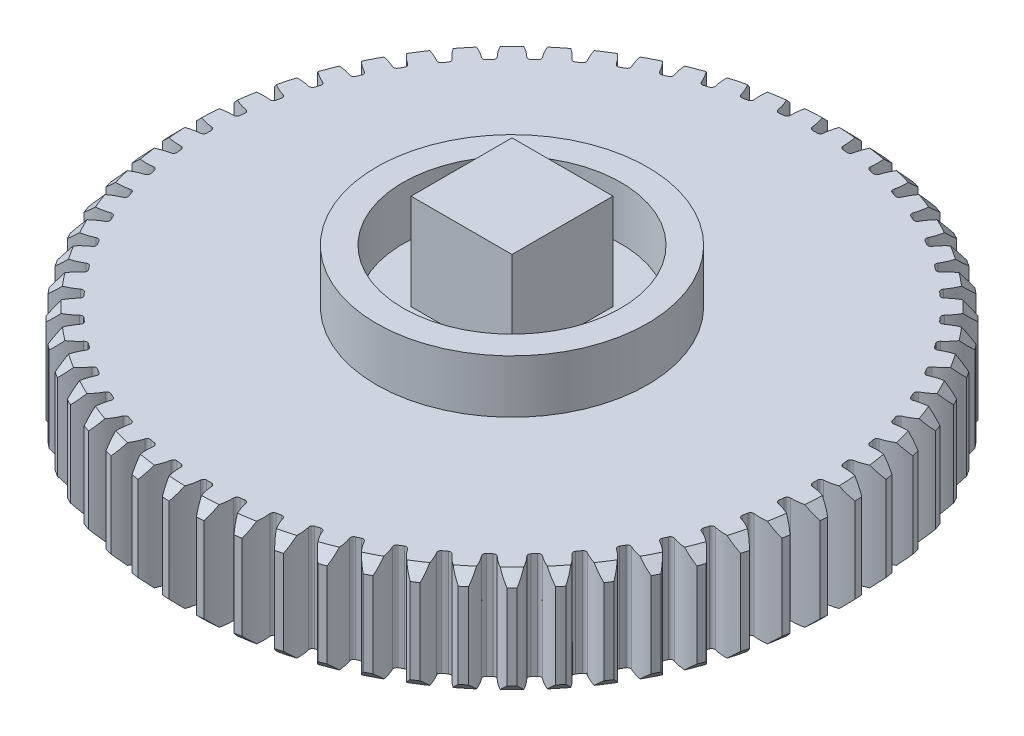
from build123d import *

# Parameters (mm, degrees)
SKETCH1_R                = 31
BOSS_EXTRUDE1_DEPTH      = 5
CUT_EXTRUDE4_DEPTH       = 6
FILLET1_R                = 0.3
CHAMFER1_SIZE            = 1
CIRPATTERN1_COUNT        = 60
FILLET1_OF_CIRPATTERN1_R = 0.3
SKETCH3_R                = 12.75
SKETCH3_R_2              = 10.25
BOSS_EXTRUDE3_DEPTH      = 5
SKETCH5_W                = 9.5
SKETCH5_H                = 9.5
BOSS_EXTRUDE4_DEPTH      = 9
SKETCH6_R                = 7.5
BOSS_EXTRUDE5_DEPTH      = 10


with BuildPart() as part:
    # Sketch1 → Boss-Extrude1 (new body, symmetric)
    with BuildSketch(Plane(origin=(0, 0, 0), x_dir=(1, 0, 0), z_dir=(0, 1, 0))):
        Circle(SKETCH1_R)
    extrude(amount=BOSS_EXTRUDE1_DEPTH, both=True)

    # Sketch2 → Cut-Extrude4 (cut, symmetric)
    with BuildSketch(Plane(origin=(0, 0, 0), x_dir=(1, 0, 0), z_dir=(0, 1, 0))):
        with BuildLine():
            ThreePointArc((-1.283727225, 30.973408666), (-0.717806781, 29.790187518), (-0.50807607, 28.495470846))
            ThreePointArc((-0.50807607, 28.495470846), (0, 28.5), (0.50807607, 28.495470846))
            ThreePointArc((0.50807607, 28.495470846), (0.717806781, 29.790187518), (1.283727225, 30.973408666))
            ThreePointArc((1.283727225, 30.973408666), (0, 31), (-1.283727225, 30.973408666))
        make_face()
    cut_extrude4 = extrude(amount=CUT_EXTRUDE4_DEPTH, both=True, mode=Mode.SUBTRACT)

    # Fillet1
    fillet1_edges = [part.edges().sort_by_distance(p)[0] for p in [
        (0.50807607, 0, -28.495470846),
        (-0.50807607, 0, -28.495470846),
    ]]
    fillet(fillet1_edges, radius=FILLET1_R)

    # Chamfer1
    chamfer1_edges = [part.edges().sort_by_distance(p)[0] for p in [
        (-21.46164551, -5, 22.369572459),
        (-21.46164551, 5, 22.369572459),
    ]]
    chamfer(chamfer1_edges, length=CHAMFER1_SIZE)

    # CirPattern1: Cut-Extrude4 ×60 about axis
    cirpattern1_axis = Axis((0, 0, 0), (0, 1, 0))
    for i in range(1, CIRPATTERN1_COUNT):
        add(cut_extrude4.rotate(cirpattern1_axis, i * 360 / CIRPATTERN1_COUNT), mode=Mode.SUBTRACT)

    # Fillet1 of CirPattern1
    fillet1_of_cirpattern1_edges = [part.edges().sort_by_distance(p)[0] for p in [
        (-2.473295002, 0, -28.392478085),
        (-3.483880553, 0, -28.286261264),
        (-5.427568136, 0, -27.978411394),
        (-6.421514913, 0, -27.767141485),
        (-8.322375697, 0, -27.257807372),
        (-9.288793811, 0, -26.943799093),
        (-11.126001569, 0, -26.238561109),
        (-12.05430274, 0, -25.825254799),
        (-13.807728639, 0, -24.93183968),
        (-14.687742206, 0, -24.42376361),
        (-16.338175345, 0, -23.351959797),
        (-17.160259695, 0, -22.754680556),
        (-18.689617583, 0, -21.516230957),
        (-19.444765787, 0, -20.83629246),
        (-20.83629246, 0, -19.444765787),
        (-21.516230957, 0, -18.689617583),
        (-22.754680556, 0, -17.160259695),
        (-23.351959797, 0, -16.338175345),
        (-24.42376361, 0, -14.687742206),
        (-24.93183968, 0, -13.807728639),
        (-25.825254799, 0, -12.05430274),
        (-26.238561109, 0, -11.126001569),
        (-26.943799093, 0, -9.288793811),
        (-27.257807372, 0, -8.322375697),
        (-27.767141485, 0, -6.421514913),
        (-27.978411394, 0, -5.427568136),
        (-28.286261264, 0, -3.483880553),
        (-28.392478085, 0, -2.473295002),
        (-28.495470846, 0, -0.50807607),
        (-28.495470846, 0, 0.50807607),
        (-28.392478085, 0, 2.473295002),
        (-28.286261264, 0, 3.483880553),
        (-27.978411394, 0, 5.427568136),
        (-27.767141485, 0, 6.421514913),
        (-27.257807372, 0, 8.322375697),
        (-26.943799093, 0, 9.288793811),
        (-26.238561109, 0, 11.126001569),
        (-25.825254799, 0, 12.05430274),
        (-24.93183968, 0, 13.807728639),
        (-24.42376361, 0, 14.687742206),
        (-23.351959797, 0, 16.338175345),
        (-22.754680556, 0, 17.160259695),
        (-21.516230957, 0, 18.689617583),
        (-20.83629246, 0, 19.444765787),
        (-19.444765787, 0, 20.83629246),
        (-18.689617583, 0, 21.516230957),
        (-17.160259695, 0, 22.754680556),
        (-16.338175345, 0, 23.351959797),
        (-14.687742206, 0, 24.42376361),
        (-13.807728639, 0, 24.93183968),
        (-12.05430274, 0, 25.825254799),
        (-11.126001569, 0, 26.238561109),
        (-9.288793811, 0, 26.943799093),
        (-8.322375697, 0, 27.257807372),
        (-6.421514913, 0, 27.767141485),
        (-5.427568136, 0, 27.978411394),
        (-3.483880553, 0, 28.286261264),
        (-2.473295002, 0, 28.392478085),
        (-0.50807607, 0, 28.495470846),
        (0.50807607, 0, 28.495470846),
        (2.473295002, 0, 28.392478085),
        (3.483880553, 0, 28.286261264),
        (5.427568136, 0, 27.978411394),
        (6.421514913, 0, 27.767141485),
        (8.322375697, 0, 27.257807372),
        (9.288793811, 0, 26.943799093),
        (11.126001569, 0, 26.238561109),
        (12.05430274, 0, 25.825254799),
        (13.807728639, 0, 24.93183968),
        (14.687742206, 0, 24.42376361),
        (16.338175345, 0, 23.351959797),
        (17.160259695, 0, 22.754680556),
        (18.689617583, 0, 21.516230957),
        (19.444765787, 0, 20.83629246),
        (20.83629246, 0, 19.444765787),
        (21.516230957, 0, 18.689617583),
        (22.754680556, 0, 17.160259695),
        (23.351959797, 0, 16.338175345),
        (24.42376361, 0, 14.687742206),
        (24.93183968, 0, 13.807728639),
        (25.825254799, 0, 12.05430274),
        (26.238561109, 0, 11.126001569),
        (26.943799093, 0, 9.288793811),
        (27.257807372, 0, 8.322375697),
        (27.767141485, 0, 6.421514913),
        (27.978411394, 0, 5.427568136),
        (28.286261264, 0, 3.483880553),
        (28.392478085, 0, 2.473295002),
        (28.495470846, 0, 0.50807607),
        (28.495470846, 0, -0.50807607),
        (28.392478085, 0, -2.473295002),
        (28.286261264, 0, -3.483880553),
        (27.978411394, 0, -5.427568136),
        (27.767141485, 0, -6.421514913),
        (27.257807372, 0, -8.322375697),
        (26.943799093, 0, -9.288793811),
        (26.238561109, 0, -11.126001569),
        (25.825254799, 0, -12.05430274),
        (24.93183968, 0, -13.807728639),
        (24.42376361, 0, -14.687742206),
        (23.351959797, 0, -16.338175345),
        (22.754680556, 0, -17.160259695),
        (21.516230957, 0, -18.689617583),
        (20.83629246, 0, -19.444765787),
        (19.444765787, 0, -20.83629246),
        (18.689617583, 0, -21.516230957),
        (17.160259695, 0, -22.754680556),
        (16.338175345, 0, -23.351959797),
        (14.687742206, 0, -24.42376361),
        (13.807728639, 0, -24.93183968),
        (12.05430274, 0, -25.825254799),
        (11.126001569, 0, -26.238561109),
        (9.288793811, 0, -26.943799093),
        (8.322375697, 0, -27.257807372),
        (6.421514913, 0, -27.767141485),
        (5.427568136, 0, -27.978411394),
        (3.483880553, 0, -28.286261264),
        (2.473295002, 0, -28.392478085),
    ]]
    fillet(fillet1_of_cirpattern1_edges, radius=FILLET1_OF_CIRPATTERN1_R)

    # Sketch3 → Boss-Extrude3 (add)
    with BuildSketch(Plane(origin=(0, 5, 0), x_dir=(1, 0, 0), z_dir=(0, 1, 0))):
        Circle(SKETCH3_R)
        Circle(SKETCH3_R_2, mode=Mode.SUBTRACT)
    extrude(amount=BOSS_EXTRUDE3_DEPTH)

    # Sketch5 → Boss-Extrude4 (add)
    with BuildSketch(Plane(origin=(0, 5, 0), x_dir=(1, 0, 0), z_dir=(0, 1, 0))):
        Rectangle(SKETCH5_W, SKETCH5_H)
    extrude(amount=BOSS_EXTRUDE4_DEPTH)

    # Sketch6 → Boss-Extrude5 (add)
    with BuildSketch(Plane.XZ.offset(5)):
        Circle(SKETCH6_R)
    extrude(amount=BOSS_EXTRUDE5_DEPTH)


solid = part.part
